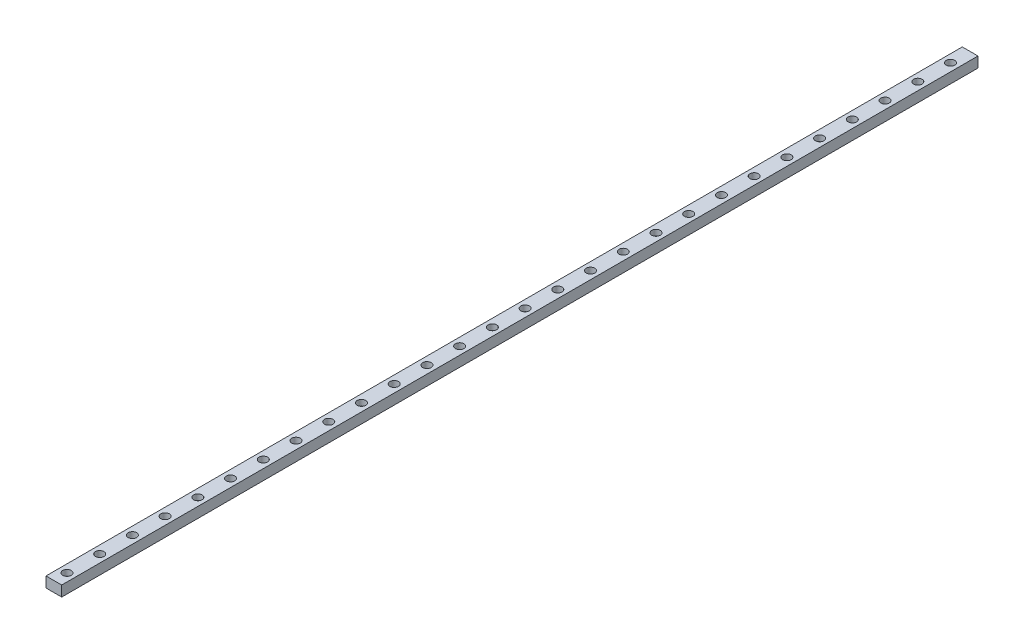
from build123d import *

# Parameters (mm, degrees)
SKETCH1_W                      = 12
SKETCH1_H                      = 8
BOSS_EXTRUDE1_DEPTH            = 700
CBORE_FOR_M3_SHCS1_D           = 3.4
CBORE_FOR_M3_SHCS1_CBORE_D     = 6.5
CBORE_FOR_M3_SHCS1_CBORE_DEPTH = 4.5


with BuildPart() as part:
    # Sketch1 → Boss-Extrude1 (new body)
    with BuildSketch(Plane.XY):
        with Locations((6, 4)):
            Rectangle(SKETCH1_W, SKETCH1_H)
    extrude(amount=BOSS_EXTRUDE1_DEPTH)

    # CBORE for M3 SHCS1 (through all)
    with Locations(Plane(origin=(0, 8, 0), x_dir=(1, 0, 0), z_dir=(0, 1, 0))):
        with Locations((6, -690), (6, -665), (6, -640), (6, -615), (6, -590), (6, -565), (6, -540), (6, -515), (6, -490), (6, -465), (6, -440), (6, -415), (6, -390), (6, -365), (6, -340), (6, -315), (6, -290), (6, -265), (6, -240), (6, -215), (6, -190), (6, -165), (6, -140), (6, -115), (6, -90), (6, -65), (6, -40), (6, -15)):
            CounterBoreHole(CBORE_FOR_M3_SHCS1_D / 2, CBORE_FOR_M3_SHCS1_CBORE_D / 2, CBORE_FOR_M3_SHCS1_CBORE_DEPTH)


solid = part.part
